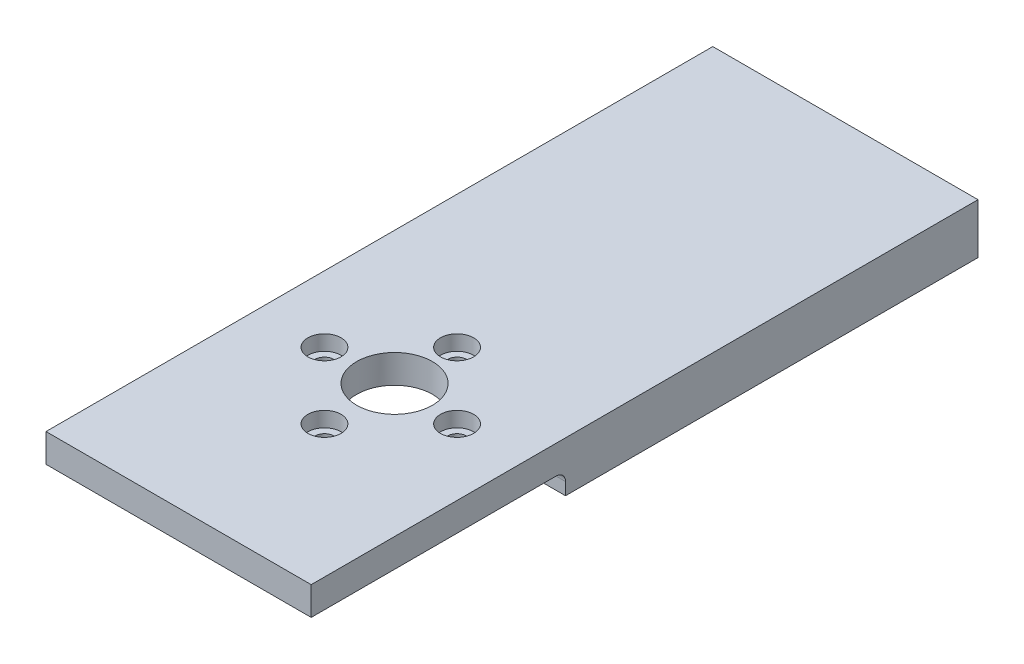
from build123d import *

# Parameters (mm, degrees)
SKETCH1_W           = 28
SKETCH1_H           = 70.4
BOSS_EXTRUDE1_DEPTH = 3
SKETCH4_R           = 1
CUT_EXTRUDE2_DEPTH  = 10
SKETCH5_R           = 4
CUT_EXTRUDE3_DEPTH  = 10
SKETCH10_R          = 1.75
CUT_EXTRUDE9_DEPTH  = 1.6
BOSS_EXTRUDE2_DEPTH = 2.3
FILLET1_R           = 1


with BuildPart() as part:
    # Sketch1 → Boss-Extrude1 (new body)
    with BuildSketch(Plane(origin=(0, 0, 0), x_dir=(1, 0, 0), z_dir=(0, 1, 0))):
        Rectangle(SKETCH1_W, SKETCH1_H)
    extrude(amount=BOSS_EXTRUDE1_DEPTH)

    # Sketch4 → Cut-Extrude2 (cut)
    with BuildSketch(Plane(origin=(0, 3, 0), x_dir=(1, 0, 0), z_dir=(0, 1, 0))):
        with Locations((7, -12.8)):
            Circle(SKETCH4_R)
        with Locations((0, -19.8)):
            Circle(SKETCH4_R)
        with Locations((-7, -12.8)):
            Circle(SKETCH4_R)
        with Locations((0, -5.8)):
            Circle(SKETCH4_R)
    extrude(amount=-CUT_EXTRUDE2_DEPTH, mode=Mode.SUBTRACT)

    # Sketch5 → Cut-Extrude3 (cut)
    with BuildSketch(Plane(origin=(0, 3, 0), x_dir=(1, 0, 0), z_dir=(0, 1, 0))):
        with Locations((0, -12.4)):
            Circle(SKETCH5_R)
    extrude(amount=-CUT_EXTRUDE3_DEPTH, mode=Mode.SUBTRACT)

    # Sketch10 → Cut-Extrude9 (cut)
    with BuildSketch(Plane(origin=(0, 3, 0), x_dir=(1, 0, 0), z_dir=(0, 1, 0))):
        with Locations((0, -19.8)):
            Circle(SKETCH10_R)
        with Locations((-7, -12.8)):
            Circle(SKETCH10_R)
        with Locations((0, -5.8)):
            Circle(SKETCH10_R)
        with Locations((7, -12.8)):
            Circle(SKETCH10_R)
    extrude(amount=-CUT_EXTRUDE9_DEPTH, mode=Mode.SUBTRACT)

    # Sketch11 → Boss-Extrude2 (add)
    with BuildSketch(Plane.XZ):
        with BuildLine():
            Line((9.143433638, 8.350602353), (14, 8.350602353))
            Line((14, 8.350602353), (14, -35.2))
            Line((14, -35.2), (-14, -35.2))
            Line((-14, -35.2), (-14, 8.350602353))
            Line((-14, 8.350602353), (-9.143433638, 8.350602353))
            ThreePointArc((-9.143433638, 8.350602353), (0, 2.4), (9.143433638, 8.350602353))
        make_face()
    extrude(amount=BOSS_EXTRUDE2_DEPTH)

    # Fillet1
    fillet1_edges = [part.edges().sort_by_distance(p)[0] for p in [
        (11.571716819, 0, 8.350602353),
        (0, 0, 2.4),
        (-11.571716819, 0, 8.350602353),
    ]]
    fillet(fillet1_edges, radius=FILLET1_R)


solid = part.part
